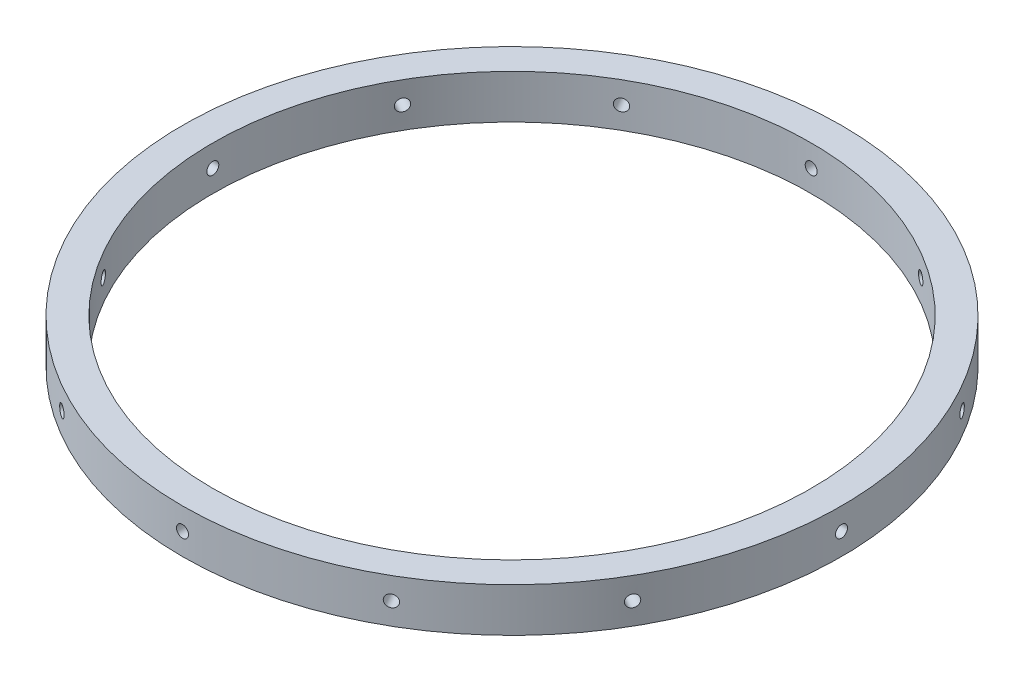
from build123d import *

# Parameters (mm, degrees)
SKETCH1_R           = 95.25
SKETCH1_R_2         = 86.487
BOSS_EXTRUDE1_DEPTH = 12.7
SKETCH3_R           = 1.7272
CUT_EXTRUDE2_DEPTH  = 254
CIRPATTERN1_COUNT   = 12


with BuildPart() as part:
    # Sketch1 → Boss-Extrude1 (new body)
    with BuildSketch(Plane(origin=(0, 0, 0), x_dir=(1, 0, 0), z_dir=(0, 1, 0))):
        Circle(SKETCH1_R)
        Circle(SKETCH1_R_2, mode=Mode.SUBTRACT)
    extrude(amount=BOSS_EXTRUDE1_DEPTH)

    # Sketch3 → Cut-Extrude2 (cut)
    with BuildSketch(Plane.XY):
        with Locations((0, 6.35)):
            Circle(SKETCH3_R)
    cut_extrude2 = extrude(amount=-CUT_EXTRUDE2_DEPTH, mode=Mode.SUBTRACT)

    # CirPattern1: Cut-Extrude2 ×12 about axis
    cirpattern1_axis = Axis((0, 12.7, 0), (0, 1, 0))
    for i in range(1, CIRPATTERN1_COUNT):
        add(cut_extrude2.rotate(cirpattern1_axis, i * 360 / CIRPATTERN1_COUNT), mode=Mode.SUBTRACT)


solid = part.part
